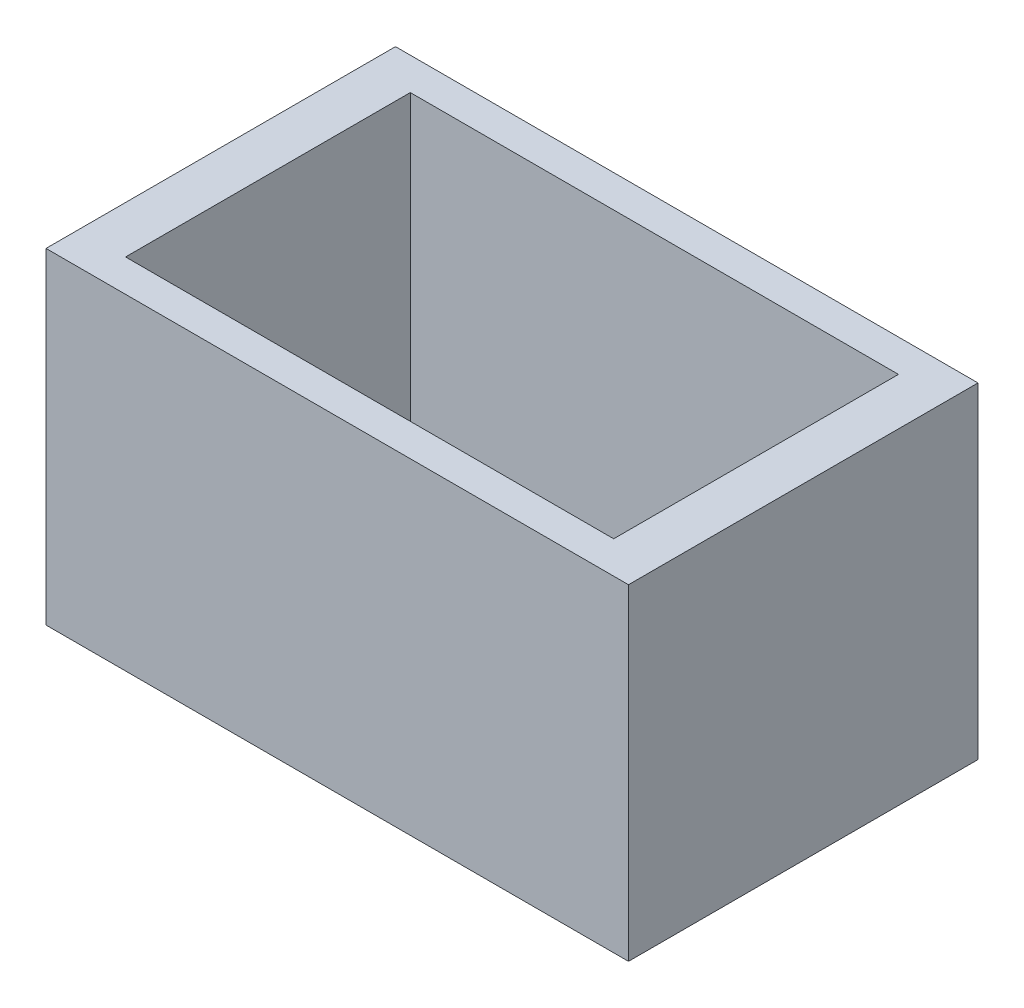
from build123d import *

# Parameters (mm, degrees)
SKETCH1_W           = 250
SKETCH1_H           = 150
BOSS_EXTRUDE1_DEPTH = 140
SKETCH2_W           = 209.504921958
SKETCH2_H           = 122.211204476
CUT_EXTRUDE1_DEPTH  = 130


with BuildPart() as part:
    # Sketch1 → Boss-Extrude1 (new body)
    with BuildSketch(Plane(origin=(0, 0, 0), x_dir=(1, 0, 0), z_dir=(0, 1, 0))):
        Rectangle(SKETCH1_W, SKETCH1_H)
    extrude(amount=BOSS_EXTRUDE1_DEPTH)

    # Sketch2 → Cut-Extrude1 (cut)
    with BuildSketch(Plane(origin=(0, 140, 0), x_dir=(1, 0, 0), z_dir=(0, 1, 0))):
        Rectangle(SKETCH2_W, SKETCH2_H)
    extrude(amount=-CUT_EXTRUDE1_DEPTH, mode=Mode.SUBTRACT)


solid = part.part
